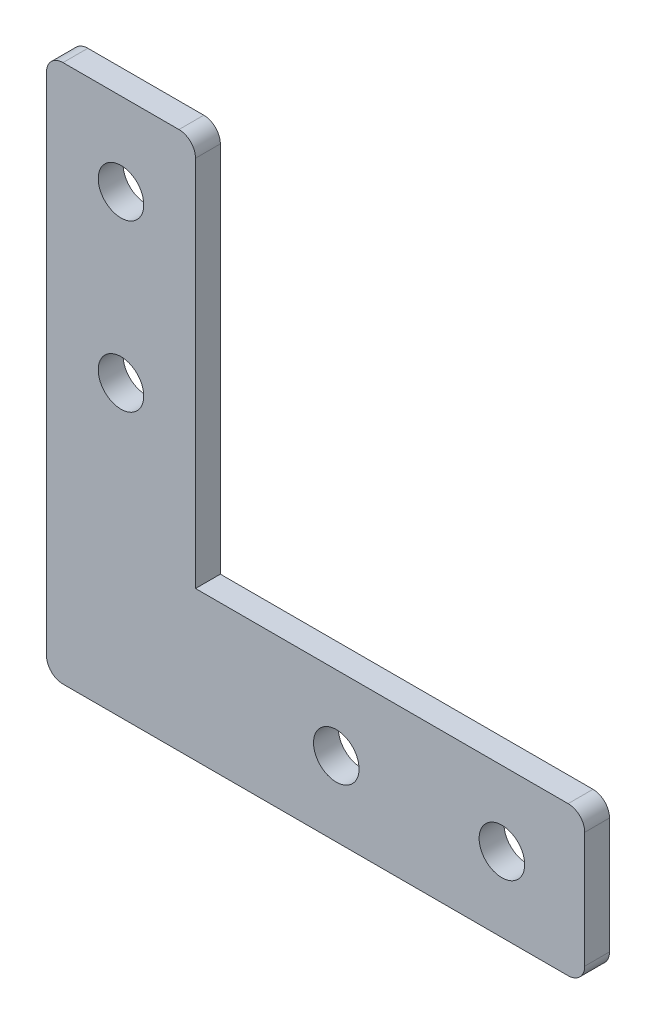
from build123d import *

# Parameters (mm, degrees)
AUFSATZ_LINEAR_AUSTRAGEN1_DEPTH = 3
DURCHGANGSLOCH_F_R_M51_D        = 5.5
VERRUNDUNG1_R                   = 2


with BuildPart() as part:
    # Skizze1 → Aufsatz-Linear austragen1 (new body)
    with BuildSketch(Plane.XY):
        Polygon((0, 0), (0, 47), (-18, 47), (-18, -18), (47, -18), (47, 0), align=None)
    extrude(amount=AUFSATZ_LINEAR_AUSTRAGEN1_DEPTH)

    # Durchgangsloch für M51 (through all)
    with Locations(Plane.XY.offset(3)):
        with Locations((17, -9), (-9, 37), (-9, 17), (37, -9)):
            Hole(DURCHGANGSLOCH_F_R_M51_D / 2)

    # Verrundung1
    verrundung1_edges = [part.edges().sort_by_distance(p)[0] for p in [
        (47, 0, 1.5),
        (47, -18, 1.5),
        (-18, -18, 1.5),
        (-18, 47, 1.5),
        (0, 47, 1.5),
    ]]
    fillet(verrundung1_edges, radius=VERRUNDUNG1_R)


solid = part.part
